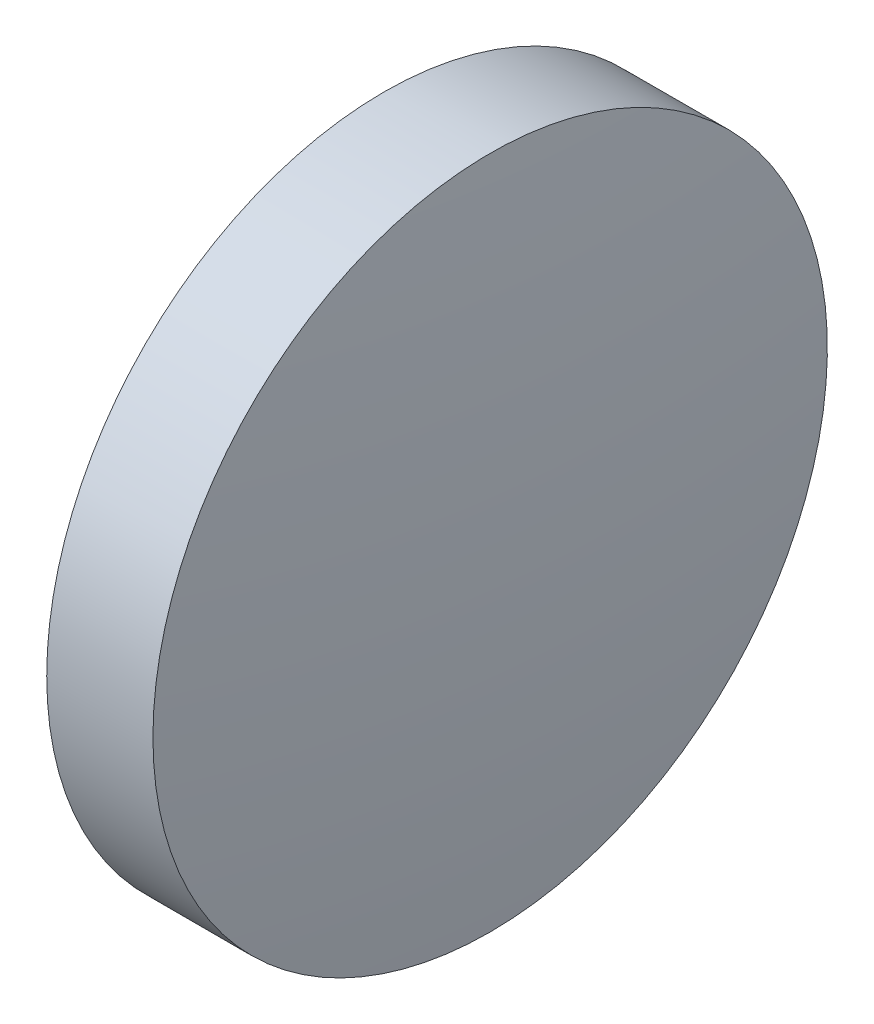
from build123d import *

# Parameters (mm, degrees)
SKETCH_1_ONE_SIDE_W = 2.000068571
SKETCH_1_ONE_SIDE_H = 6.35


with BuildPart() as part:
    # 草图1 one side → 旋转1 (revolve)
    with BuildSketch(Plane.XY, mode=Mode.PRIVATE) as revolve_1_sk:
        with Locations((43.229096888, 27.483056512)):
            Rectangle(SKETCH_1_ONE_SIDE_W, SKETCH_1_ONE_SIDE_H)
        with BuildLine():
            Line((41.879268316, 24.308056512), (42.229062602, 24.308056512))
            Line((42.229062602, 24.308056512), (42.229062602, 30.658056512))
            ThreePointArc((42.229062602, 30.658056512), (41.966783126, 27.48787003), (41.879268316, 24.308056512))
        make_face()
        with BuildLine():
            Line((44.229131173, 24.308056512), (44.578925459, 24.308056512))
            ThreePointArc((44.578925459, 24.308056512), (44.491410649, 27.48787003), (44.229131173, 30.658056512))
            Line((44.229131173, 30.658056512), (44.229131173, 24.308056512))
        make_face()
    revolve(revolve_1_sk.sketch.rotate(Axis((39.652700675, 24.308056512, 0), (1, 0, 0)), 90), axis=Axis((39.652700675, 24.308056512, 0), (1, 0, 0)))  # turned: the seam where the file's is


solid = part.part
